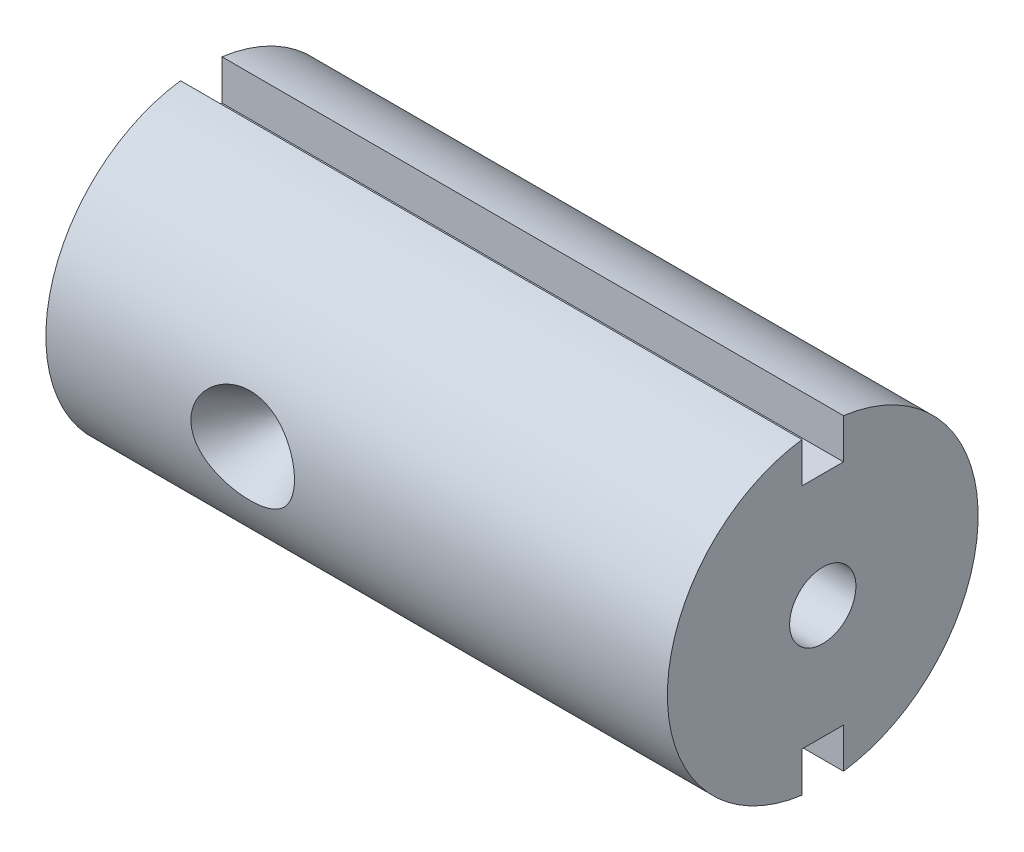
from build123d import *

# Parameters (mm, degrees)
ESQUISSE1_R             = 7.5
BOSS_EXTRU_1_DEPTH      = 30
ESQUISSE4_R             = 1.6
ENL_V_MAT_EXTRU_2_DEPTH = 32.819805295
ESQUISSE5_W             = 2
ESQUISSE5_H             = 2.6861835
ENL_V_MAT_EXTRU_3_DEPTH = 32.819805295


with BuildPart() as part:
    # Esquisse1 → Boss.-Extru.1 (new body)
    with BuildSketch(Plane(origin=(0, 0, 0), x_dir=(0, 0, -1), z_dir=(1, 0, 0))):
        Circle(ESQUISSE1_R)
    extrude(amount=BOSS_EXTRU_1_DEPTH)

    # Enlèv. mat.-Extru.1 cone 1 section (through the dimple's axis) → Enlèv. mat.-Extru.1 (revolve, cut)
    with BuildSketch(Plane(origin=(9.5, 0, 7.5), x_dir=(0, -1, 0), z_dir=(1, 0, 0))):
        Polygon((0, 0), (2.5, 0), (0, 4.330127019), align=None)
    revolve(axis=Axis((9.5, 0, 7.5), (0, 0, -1)), mode=Mode.SUBTRACT)

    # Esquisse4 → Enlèv. mat.-Extru.2 (cut, through all)
    with BuildSketch(Plane.ZY):
        Circle(ESQUISSE4_R)
    extrude(amount=-ENL_V_MAT_EXTRU_2_DEPTH, mode=Mode.SUBTRACT)

    # Esquisse5 → Enlèv. mat.-Extru.3 (cut, through all)
    with BuildSketch(Plane(origin=(30, 0, 0), x_dir=(0, 0, -1), z_dir=(1, 0, 0))):
        with Locations((0, 6.84309175)):
            Rectangle(ESQUISSE5_W, ESQUISSE5_H)
        with Locations((0, -6.84309175)):
            Rectangle(ESQUISSE5_W, ESQUISSE5_H)
    extrude(amount=-ENL_V_MAT_EXTRU_3_DEPTH, mode=Mode.SUBTRACT)


solid = part.part
